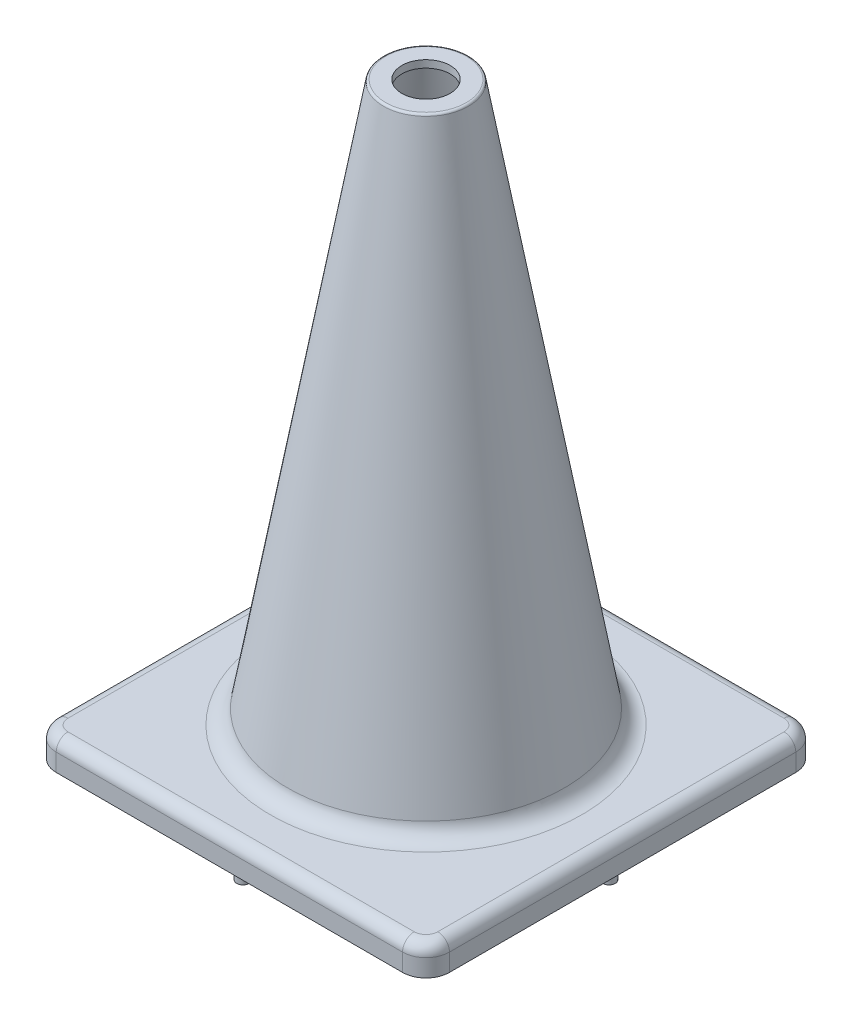
from build123d import *

# Parameters (mm, degrees)
BOSS_EXTRUDE1_DEPTH = 15.875
FILLET1_R           = 6.35
CUT_EXTRUDE1_DEPTH  = 11.90625
BOSS_EXTRUDE2_DEPTH = 11.90625
BOSS_EXTRUDE3_REACH = 25.019
FILLET2_R           = 4.7625


with BuildPart() as part:
    # Sketch1 → Boss-Extrude1 (new body)
    with BuildSketch(Plane(origin=(0, 0, 0), x_dir=(1, 0, 0), z_dir=(0, 1, 0))):
        with BuildLine():
            Line((-93.6625, -106.3625), (93.6625, -106.3625))
            ThreePointArc((93.6625, -106.3625), (102.642756121, -102.642756121), (106.3625, -93.6625))
            Line((106.3625, -93.6625), (106.3625, 93.6625))
            ThreePointArc((106.3625, 93.6625), (102.642756121, 102.642756121), (93.6625, 106.3625))
            Line((93.6625, 106.3625), (-93.6625, 106.3625))
            ThreePointArc((-93.6625, 106.3625), (-102.642756121, 102.642756121), (-106.3625, 93.6625))
            Line((-106.3625, 93.6625), (-106.3625, -93.6625))
            ThreePointArc((-106.3625, -93.6625), (-102.642756121, -102.642756121), (-93.6625, -106.3625))
        make_face()
    extrude(amount=BOSS_EXTRUDE1_DEPTH)

    # Fillet1
    fillet1_edges = [part.edges().sort_by_distance(p)[0] for p in [
        (102.642756121, 15.875, 102.642756121),
        (106.3625, 15.875, 0),
        (102.642756121, 15.875, -102.642756121),
        (0, 15.875, -106.3625),
        (-102.642756121, 15.875, -102.642756121),
        (-106.3625, 15.875, 0),
        (-102.642756121, 15.875, 102.642756121),
        (0, 15.875, 106.3625),
    ]]
    fillet(fillet1_edges, radius=FILLET1_R)

    # Sketch2 → Cut-Extrude1 (cut)
    with BuildSketch(Plane.XZ):
        Polygon((-102.39375, 95.097291902), (-95.097291902, 102.39375), (95.097291902, 102.39375), (102.39375, 95.097291902), (102.39375, -95.097291902), (95.097291902, -102.39375), (-95.097291902, -102.39375), (-102.39375, -95.097291902), align=None)
    extrude(amount=-CUT_EXTRUDE1_DEPTH, mode=Mode.SUBTRACT)

    # Sketch3 → Boss-Extrude2 (add)
    with BuildSketch(Plane.XZ.offset(-11.90625)):
        with BuildLine():
            Line((-3.3734375, 102.39375), (-3.3734375, 86.7171875))
            ThreePointArc((-3.3734375, 86.7171875), (0, 83.34375), (3.3734375, 86.7171875))
            Line((3.3734375, 86.7171875), (3.3734375, 102.39375))
            Line((3.3734375, 102.39375), (-3.3734375, 102.39375))
        make_face()
        with BuildLine():
            Line((102.39375, -3.3734375), (86.7171875, -3.3734375))
            ThreePointArc((86.7171875, -3.3734375), (83.34375, 0), (86.7171875, 3.3734375))
            Line((86.7171875, 3.3734375), (102.39375, 3.3734375))
            Line((102.39375, 3.3734375), (102.39375, -3.3734375))
        make_face()
        with BuildLine():
            Line((-3.3734375, -102.39375), (-3.3734375, -86.7171875))
            ThreePointArc((-3.3734375, -86.7171875), (0, -83.34375), (3.3734375, -86.7171875))
            Line((3.3734375, -86.7171875), (3.3734375, -102.39375))
            Line((3.3734375, -102.39375), (-3.3734375, -102.39375))
        make_face()
        with BuildLine():
            Line((-102.39375, 3.3734375), (-86.7171875, 3.3734375))
            ThreePointArc((-86.7171875, 3.3734375), (-83.34375, 0), (-86.7171875, -3.3734375))
            Line((-86.7171875, -3.3734375), (-102.39375, -3.3734375))
            Line((-102.39375, -3.3734375), (-102.39375, 3.3734375))
        make_face()
    extrude(amount=BOSS_EXTRUDE2_DEPTH)

    # Sketch4 → Boss-Extrude3 (add, up to next)
    with BuildSketch(Plane(origin=(0, -7.14375, 0), x_dir=(-1, 0, 0), z_dir=(0, -1, 0)), mode=Mode.PRIVATE) as boss_extrude3_sk1:
        with BuildLine():
            Line((-94.816658898, 90.045897834), (-63.666395478, 58.895634414))
            ThreePointArc((-63.666395478, 58.895634414), (-58.895634414, 58.895634414), (-58.895634414, 63.666395478))
            Line((-58.895634414, 63.666395478), (-90.045897834, 94.816658898))
            ThreePointArc((-90.045897834, 94.816658898), (-94.816658898, 94.816658898), (-94.816658898, 90.045897834))
        make_face()
    boss_extrude3_tool1 = extrude(boss_extrude3_sk1.sketch, amount=-BOSS_EXTRUDE3_REACH, mode=Mode.PRIVATE) - part.part
    add(boss_extrude3_tool1.solids().sort_by_distance((76.856147, -7.14375, -76.856147))[0])
    # Sketch4 → Boss-Extrude3 (add, up to next)
    with BuildSketch(Plane(origin=(0, -7.14375, 0), x_dir=(-1, 0, 0), z_dir=(0, -1, 0)), mode=Mode.PRIVATE) as boss_extrude3_sk2:
        with BuildLine():
            Line((3.3734375, 86.7171875), (3.3734375, 99.0203125))
            ThreePointArc((3.3734375, 99.0203125), (0, 102.39375), (-3.3734375, 99.0203125))
            Line((-3.3734375, 99.0203125), (-3.3734375, 86.7171875))
            ThreePointArc((-3.3734375, 86.7171875), (0, 83.34375), (3.3734375, 86.7171875))
        make_face()
    boss_extrude3_tool2 = extrude(boss_extrude3_sk2.sketch, amount=-BOSS_EXTRUDE3_REACH, mode=Mode.PRIVATE) - part.part
    add(boss_extrude3_tool2.solids().sort_by_distance((0, -7.14375, -92.86875))[0])
    # Sketch4 → Boss-Extrude3 (add, up to next)
    with BuildSketch(Plane(origin=(0, -7.14375, 0), x_dir=(-1, 0, 0), z_dir=(0, -1, 0)), mode=Mode.PRIVATE) as boss_extrude3_sk3:
        with BuildLine():
            Line((90.045897834, 94.816658898), (58.895634414, 63.666395478))
            ThreePointArc((58.895634414, 63.666395478), (58.895634414, 58.895634414), (63.666395478, 58.895634414))
            Line((63.666395478, 58.895634414), (94.816658898, 90.045897834))
            ThreePointArc((94.816658898, 90.045897834), (94.816658898, 94.816658898), (90.045897834, 94.816658898))
        make_face()
    boss_extrude3_tool3 = extrude(boss_extrude3_sk3.sketch, amount=-BOSS_EXTRUDE3_REACH, mode=Mode.PRIVATE) - part.part
    add(boss_extrude3_tool3.solids().sort_by_distance((-76.856147, -7.14375, -76.856147))[0])
    # Sketch4 → Boss-Extrude3 (add, up to next)
    with BuildSketch(Plane(origin=(0, -7.14375, 0), x_dir=(-1, 0, 0), z_dir=(0, -1, 0)), mode=Mode.PRIVATE) as boss_extrude3_sk4:
        with BuildLine():
            Line((86.7171875, -3.3734375), (99.0203125, -3.3734375))
            ThreePointArc((99.0203125, -3.3734375), (102.39375, 0), (99.0203125, 3.3734375))
            Line((99.0203125, 3.3734375), (86.7171875, 3.3734375))
            ThreePointArc((86.7171875, 3.3734375), (83.34375, 0), (86.7171875, -3.3734375))
        make_face()
    boss_extrude3_tool4 = extrude(boss_extrude3_sk4.sketch, amount=-BOSS_EXTRUDE3_REACH, mode=Mode.PRIVATE) - part.part
    add(boss_extrude3_tool4.solids().sort_by_distance((-92.86875, -7.14375, 0))[0])
    # Sketch4 → Boss-Extrude3 (add, up to next)
    with BuildSketch(Plane(origin=(0, -7.14375, 0), x_dir=(-1, 0, 0), z_dir=(0, -1, 0)), mode=Mode.PRIVATE) as boss_extrude3_sk5:
        with BuildLine():
            Line((94.816658898, -90.045897834), (63.666395478, -58.895634414))
            ThreePointArc((63.666395478, -58.895634414), (58.895634414, -58.895634414), (58.895634414, -63.666395478))
            Line((58.895634414, -63.666395478), (90.045897834, -94.816658898))
            ThreePointArc((90.045897834, -94.816658898), (94.816658898, -94.816658898), (94.816658898, -90.045897834))
        make_face()
    boss_extrude3_tool5 = extrude(boss_extrude3_sk5.sketch, amount=-BOSS_EXTRUDE3_REACH, mode=Mode.PRIVATE) - part.part
    add(boss_extrude3_tool5.solids().sort_by_distance((-76.856147, -7.14375, 76.856147))[0])
    # Sketch4 → Boss-Extrude3 (add, up to next)
    with BuildSketch(Plane(origin=(0, -7.14375, 0), x_dir=(-1, 0, 0), z_dir=(0, -1, 0)), mode=Mode.PRIVATE) as boss_extrude3_sk6:
        with BuildLine():
            Line((-3.3734375, -86.7171875), (-3.3734375, -99.0203125))
            ThreePointArc((-3.3734375, -99.0203125), (0, -102.39375), (3.3734375, -99.0203125))
            Line((3.3734375, -99.0203125), (3.3734375, -86.7171875))
            ThreePointArc((3.3734375, -86.7171875), (0, -83.34375), (-3.3734375, -86.7171875))
        make_face()
    boss_extrude3_tool6 = extrude(boss_extrude3_sk6.sketch, amount=-BOSS_EXTRUDE3_REACH, mode=Mode.PRIVATE) - part.part
    add(boss_extrude3_tool6.solids().sort_by_distance((0, -7.14375, 92.86875))[0])
    # Sketch4 → Boss-Extrude3 (add, up to next)
    with BuildSketch(Plane(origin=(0, -7.14375, 0), x_dir=(-1, 0, 0), z_dir=(0, -1, 0)), mode=Mode.PRIVATE) as boss_extrude3_sk7:
        with BuildLine():
            Line((-90.045897834, -94.816658898), (-58.895634414, -63.666395478))
            ThreePointArc((-58.895634414, -63.666395478), (-58.895634414, -58.895634414), (-63.666395478, -58.895634414))
            Line((-63.666395478, -58.895634414), (-94.816658898, -90.045897834))
            ThreePointArc((-94.816658898, -90.045897834), (-94.816658898, -94.816658898), (-90.045897834, -94.816658898))
        make_face()
    boss_extrude3_tool7 = extrude(boss_extrude3_sk7.sketch, amount=-BOSS_EXTRUDE3_REACH, mode=Mode.PRIVATE) - part.part
    add(boss_extrude3_tool7.solids().sort_by_distance((76.856147, -7.14375, 76.856147))[0])
    # Sketch4 → Boss-Extrude3 (add, up to next)
    with BuildSketch(Plane(origin=(0, -7.14375, 0), x_dir=(-1, 0, 0), z_dir=(0, -1, 0)), mode=Mode.PRIVATE) as boss_extrude3_sk8:
        with BuildLine():
            Line((-86.7171875, 3.3734375), (-99.0203125, 3.3734375))
            ThreePointArc((-99.0203125, 3.3734375), (-102.39375, 0), (-99.0203125, -3.3734375))
            Line((-99.0203125, -3.3734375), (-86.7171875, -3.3734375))
            ThreePointArc((-86.7171875, -3.3734375), (-83.34375, 0), (-86.7171875, 3.3734375))
        make_face()
    boss_extrude3_tool8 = extrude(boss_extrude3_sk8.sketch, amount=-BOSS_EXTRUDE3_REACH, mode=Mode.PRIVATE) - part.part
    add(boss_extrude3_tool8.solids().sort_by_distance((92.86875, -7.14375, 0))[0])

    # Fillet2
    fillet2_edges = [part.edges().sort_by_distance(p)[0] for p in [
        (49.235364701, 11.90625, -102.39375),
        (-102.39375, 11.90625, -49.235364701),
        (-102.39375, 11.90625, 49.235364701),
        (-98.745520951, 11.90625, 98.745520951),
        (49.235364701, 11.90625, 102.39375),
        (98.745520951, 11.90625, 98.745520951),
        (102.39375, 11.90625, -49.235364701),
        (98.745520951, 11.90625, -98.745520951),
        (-49.235364701, 11.90625, -102.39375),
        (-98.745520951, 11.90625, -98.745520951),
        (-49.235364701, 11.90625, 102.39375),
        (102.39375, 11.90625, 49.235364701),
    ]]
    fillet(fillet2_edges, radius=FILLET2_R)

    # Sketch5 → Revolve1 (revolve)
    with BuildSketch(Plane.XY):
        with BuildLine():
            Line((74.811263488, 23.744742818), (23.01875, 317.244450958))
            ThreePointArc((23.01875, 317.244450958), (22.584348758, 317.996681194), (21.768073748, 318.29375))
            Line((21.768073748, 318.29375), (13.096875, 318.29375))
            Line((13.096875, 318.29375), (13.096875, 314.325))
            Line((13.096875, 314.325), (19.503862058, 314.325))
            Line((19.503862058, 314.325), (72.169930274, 15.875))
            Line((72.169930274, 15.875), (84.191335378, 15.875))
            ThreePointArc((84.191335378, 15.875), (78.069272803, 18.103016046), (74.811263488, 23.744742818))
        make_face()
    revolve(axis=Axis((0, 0, 0), (0, 1, 0)))

    # Sketch6 → Cut-Revolve1 (revolve, cut)
    with BuildSketch(Plane.XY):
        with BuildLine():
            Line((0, 21.121495212), (71.244105933, 21.121495212))
            Line((71.244105933, 21.121495212), (71.481540414, 19.775992818))
            ThreePointArc((71.481540414, 19.775992818), (74.739549729, 14.134266046), (80.861612304, 11.90625))
            Line((80.861612304, 11.90625), (0, 11.90625))
            Line((0, 11.90625), (0, 21.121495212))
        make_face()
    revolve(axis=Axis((0, 11.90625, 0), (0, 1, 0)), mode=Mode.SUBTRACT)


solid = part.part
